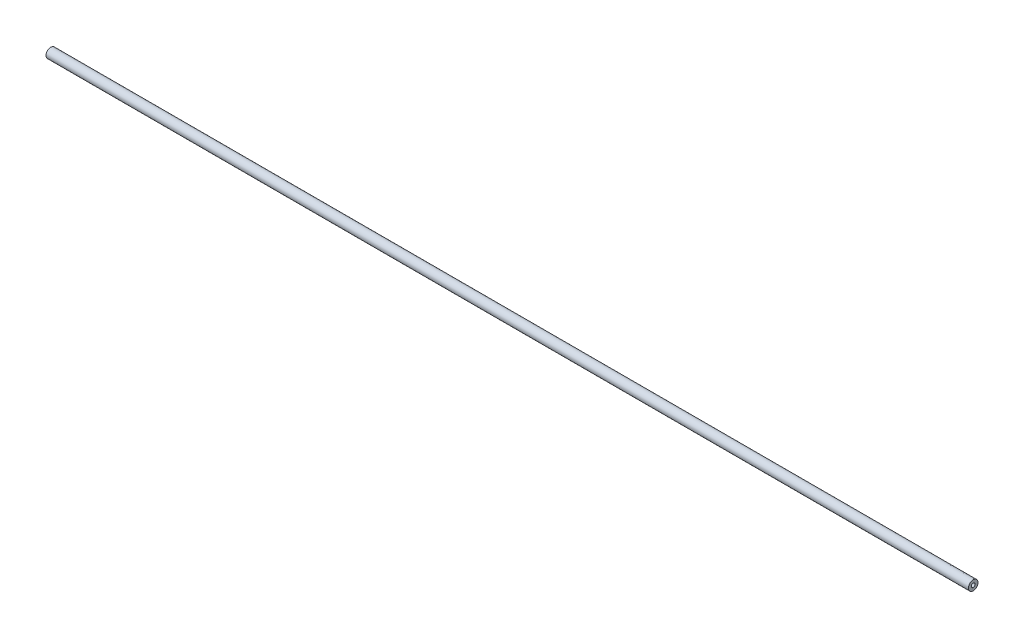
from build123d import *


with BuildPart() as part:
    # Skizze1 → Rotation1 (revolve)
    with BuildSketch(Plane.XY):
        Polygon((3, 1.6), (0, 1.6), (0, 0), (-764, 0), (-764, 1.6), (-767, 1.6), (-767, 4), (3, 4), align=None)
    revolve(axis=Axis((0, 0, 0), (-1, 0, 0)))


solid = part.part
